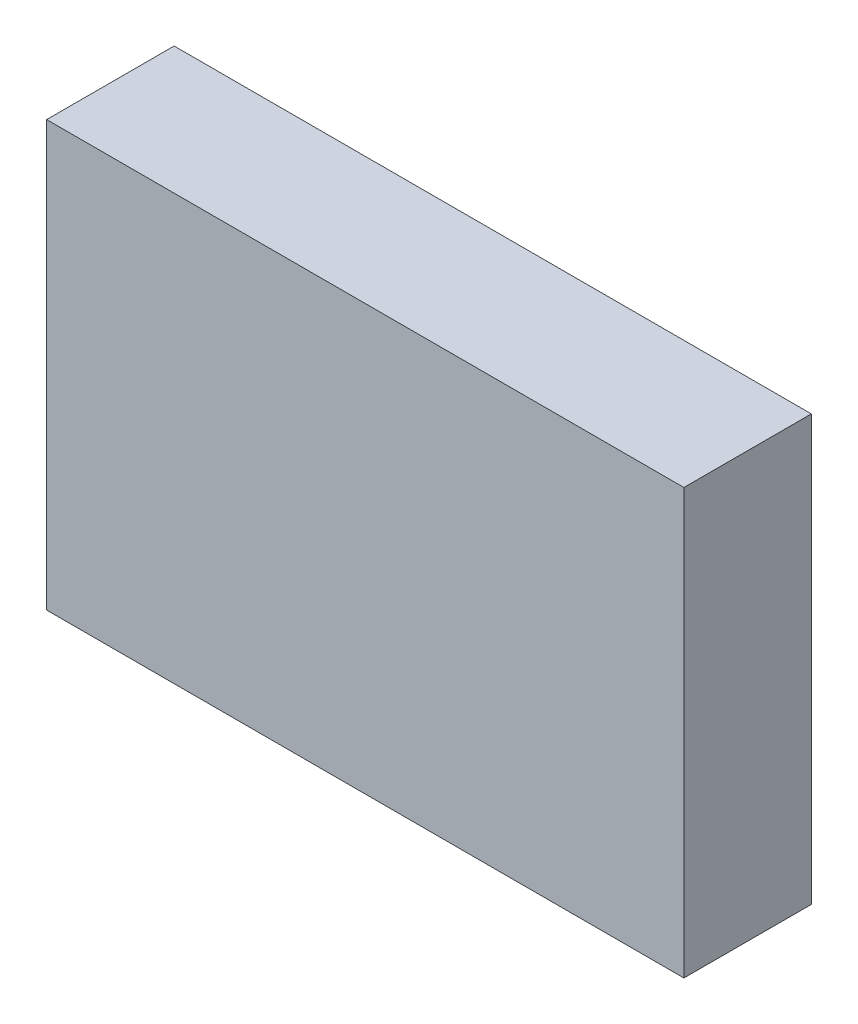
from build123d import *

# Parameters (mm, degrees)
SKETCH_1_W          = 60
SKETCH_1_H          = 40
EXTRUDE_1_DEPTH     = 12
SKETCH_2_R          = 10
CUT_EXTRUDE_1_DEPTH = 3


with BuildPart() as part:
    # 草图1 → 凸台-拉伸1 (new body)
    with BuildSketch(Plane.XY):
        Rectangle(SKETCH_1_W, SKETCH_1_H)
    extrude(amount=EXTRUDE_1_DEPTH)

    # 草图2 → 切除-拉伸1 (cut)
    with BuildSketch(Plane(origin=(0, 0, 0), x_dir=(-1, 0, 0), z_dir=(0, 0, -1))):
        Circle(SKETCH_2_R)
    extrude(amount=-CUT_EXTRUDE_1_DEPTH, mode=Mode.SUBTRACT)


solid = part.part
